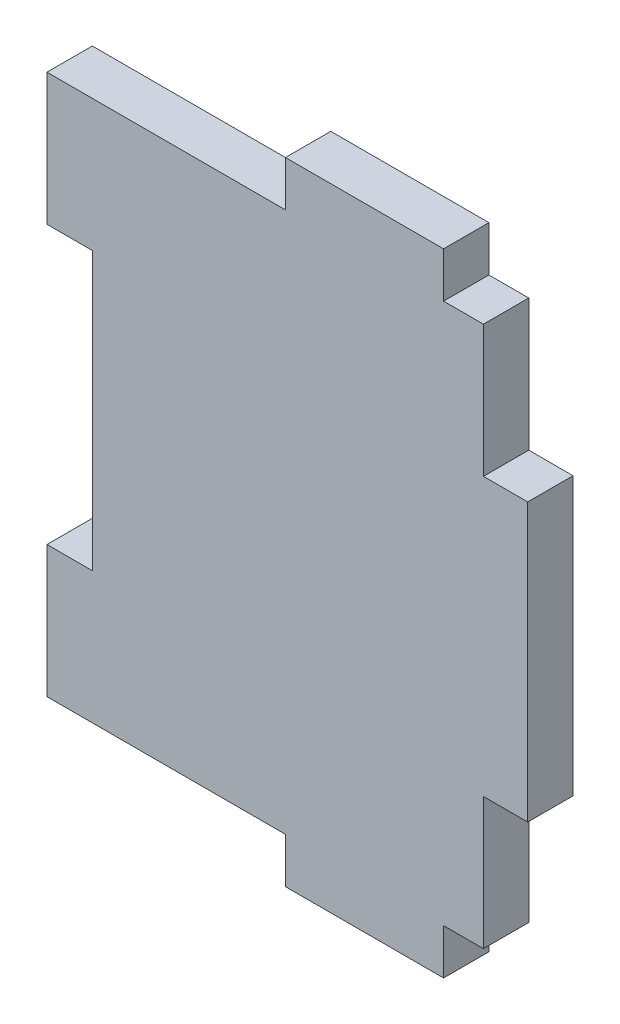
from build123d import *

# Parameters (mm, degrees)
SKETCH1_W           = 5.334
SKETCH1_H           = 33.401
BOSS_EXTRUDE1_DEPTH = 5.461
SKETCH2_W           = 19.05
SKETCH2_H           = 5.461
BOSS_EXTRUDE2_DEPTH = 5.461


with BuildPart() as part:
    # Sketch1 → Boss-Extrude1 (new body)
    with BuildSketch(Plane.XY):
        Polygon((26.289, 32.5755), (-26.289, 32.5755), (-26.289, 16.7005), (-20.828, 16.7005), (-20.828, -16.7005), (-26.289, -16.7005), (-26.289, -32.5755), (26.289, -32.5755), (26.289, -16.7005), (26.289, 16.7005), align=None)
        with Locations((28.956, 0)):
            Rectangle(SKETCH1_W, SKETCH1_H)
    extrude(amount=BOSS_EXTRUDE1_DEPTH)

    # Sketch2 → Boss-Extrude2 (add)
    with BuildSketch(Plane.XY.offset(5.461)):
        with Locations((11.9634, 35.306)):
            Rectangle(SKETCH2_W, SKETCH2_H)
        with Locations((11.9634, -35.306)):
            Rectangle(SKETCH2_W, SKETCH2_H)
    extrude(amount=-BOSS_EXTRUDE2_DEPTH)


solid = part.part
